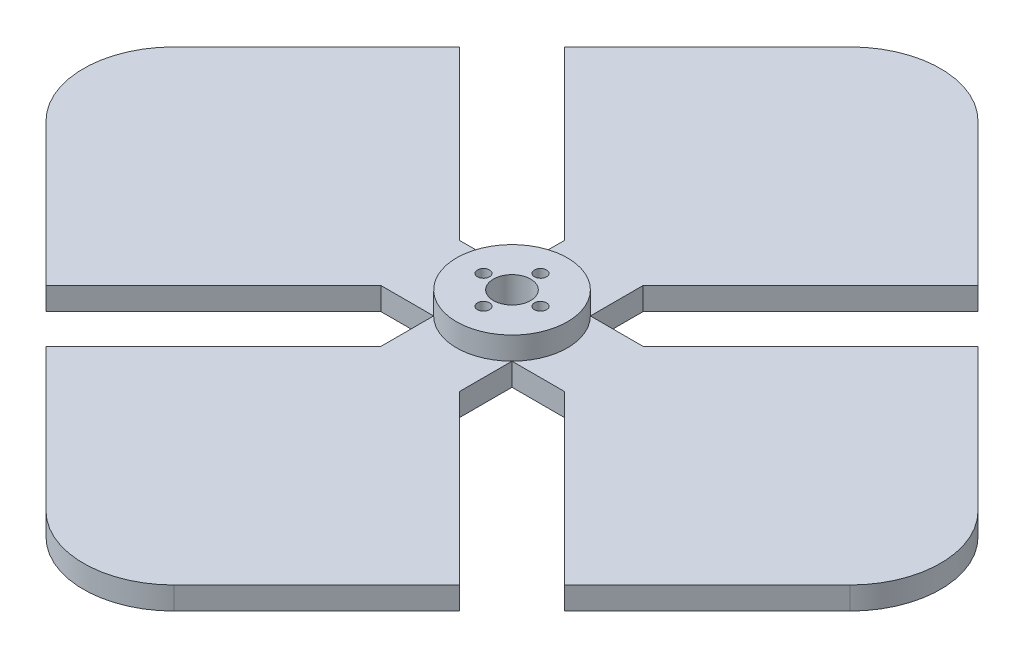
from build123d import *

# Parameters (mm, degrees)
BOSS_EXTRUDE5_DEPTH      = 6.35
FILLET1_R                = 25.4
CIRPATTERN7_COUNT        = 4
FILLET1_OF_CIRPATTERN7_R = 25.4
SKETCH13_R               = 15.556349186
BOSS_EXTRUDE8_DEPTH      = 6.35
SKETCH1_R                = 5.22699996
SKETCH1_R_2              = 1.686500056
CUT_EXTRUDE1_DEPTH       = 13.7


with BuildPart() as part:
    # Sketch4 → Boss-Extrude5 (new body)
    with BuildSketch(Plane(origin=(0, 0, 0), x_dir=(1, 0, 0), z_dir=(0, 1, 0))):
        Polygon((25.7955, 11), (25.7955, -11), (72.807954542, -58.012454542), (130.820409084, 0), (72.807954542, 58.012454542), align=None)
        Polygon((25.7955, 11), (14.7955, 0), (25.7955, -11), align=None)
        Polygon((25.7955, -11), (14.7955, 0), (25.7955, 11), (0, 11), (0, -11), align=None)
    boss_extrude5 = extrude(amount=BOSS_EXTRUDE5_DEPTH)

    # Fillet1
    fillet1_edges = [part.edges().sort_by_distance(p)[0] for p in [
        (130.820409084, 3.175, 0),
    ]]
    fillet(fillet1_edges, radius=FILLET1_R)

    # CirPattern7: Boss-Extrude5 ×4 about axis
    cirpattern7_axis = Axis((0, 0, 0), (0, 1, 0))
    for i in range(1, CIRPATTERN7_COUNT):
        add(boss_extrude5.rotate(cirpattern7_axis, i * 360 / CIRPATTERN7_COUNT))

    # Fillet1 of CirPattern7
    fillet1_of_cirpattern7_edges = [part.edges().sort_by_distance(p)[0] for p in [
        (0, 3.175, -130.820409084),
        (-130.820409084, 3.175, 0),
        (0, 3.175, 130.820409084),
    ]]
    fillet(fillet1_of_cirpattern7_edges, radius=FILLET1_OF_CIRPATTERN7_R)

    # Sketch13 → Boss-Extrude8 (add)
    with BuildSketch(Plane(origin=(0, 6.35, 0), x_dir=(1, 0, 0), z_dir=(0, 1, 0))):
        Circle(SKETCH13_R)
    extrude(amount=BOSS_EXTRUDE8_DEPTH)

    # Sketch1 → Cut-Extrude1 (cut, through all)
    with BuildSketch(Plane(origin=(0, 0, 0), x_dir=(1, 0, 0), z_dir=(0, 1, 0))):
        Circle(SKETCH1_R)
        with Locations((8.000000002, 0)):
            Circle(SKETCH1_R_2)
        with Locations((0, -8.000000002)):
            Circle(SKETCH1_R_2)
        with Locations((-8.000000002, 0)):
            Circle(SKETCH1_R_2)
        with Locations((0, 8.000000002)):
            Circle(SKETCH1_R_2)
    extrude(amount=CUT_EXTRUDE1_DEPTH, mode=Mode.SUBTRACT)


solid = part.part
